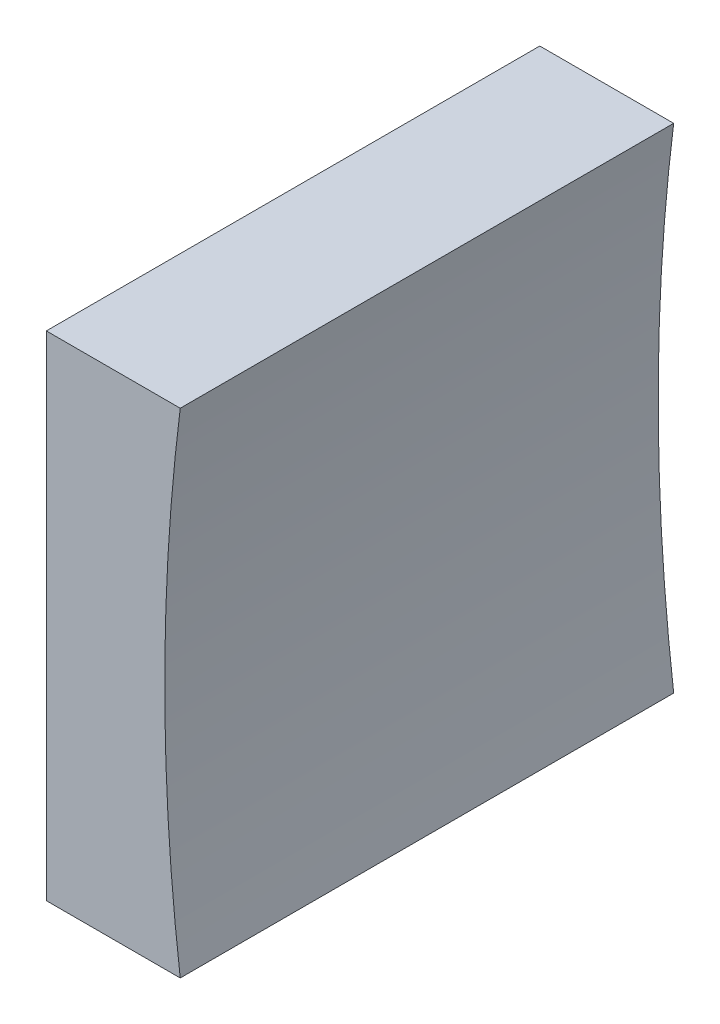
from build123d import *

# Parameters (mm, degrees)
EXTRUDE_1_DEPTH = 25


with BuildPart() as part:
    # 草图1 → 凸台-拉伸1 (new body)
    with BuildSketch(Plane.XY):
        with BuildLine():
            Line((284.707135631, 66.857929268), (284.707135631, 79.357929268))
            Line((284.707135631, 79.357929268), (291.491461496, 79.357929268))
            ThreePointArc((291.491461496, 79.357929268), (290.707135661, 66.857929268), (291.491461496, 54.357929268))
            Line((291.491461496, 54.357929268), (284.707135631, 54.357929268))
            Line((284.707135631, 54.357929268), (284.707135631, 66.857929268))
        make_face()
    extrude(amount=EXTRUDE_1_DEPTH)


solid = part.part
